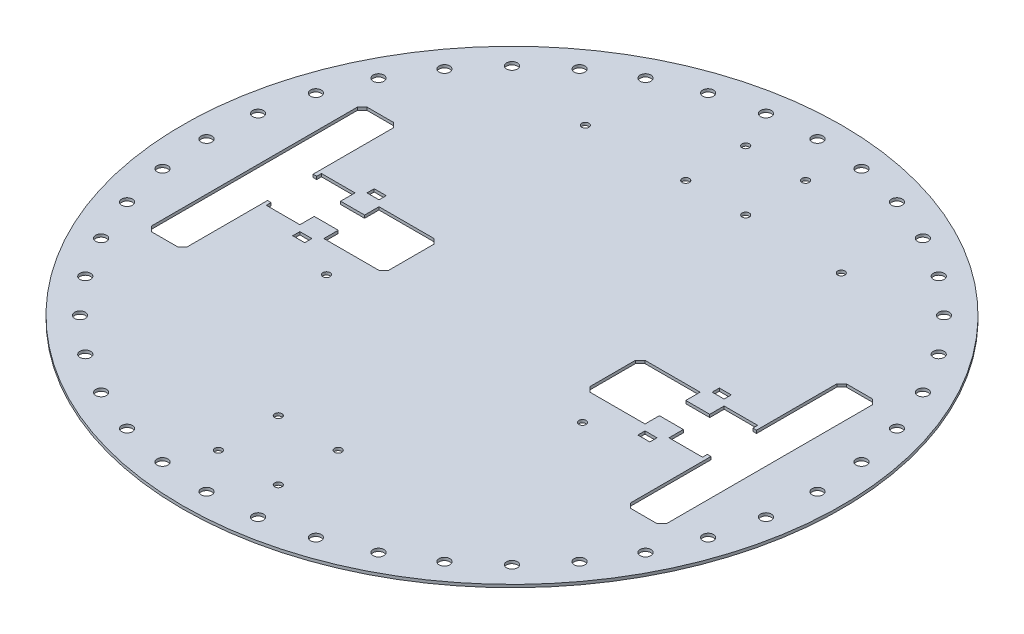
from build123d import *

# Parameters (mm, degrees)
SKETCH1_R           = 137.5
BOSS_EXTRUDE1_DEPTH = 1.2
SKETCH3_R           = 2.25
CUT_EXTRUDE1_DEPTH  = 2.2
CUT_EXTRUDE2_DEPTH  = 1.2
SKETCH5_R           = 1.5
CUT_EXTRUDE3_DEPTH  = 2.2
SKETCH6_R           = 1.5
CUT_EXTRUDE4_DEPTH  = 2.2
SKETCH7_W           = 5
SKETCH7_H           = 3
CUT_EXTRUDE5_DEPTH  = 2.2


with BuildPart() as part:
    # Sketch1 → Boss-Extrude1 (new body)
    with BuildSketch(Plane(origin=(0, 0, 0), x_dir=(1, 0, 0), z_dir=(0, 1, 0))):
        Circle(SKETCH1_R)
    extrude(amount=BOSS_EXTRUDE1_DEPTH)

    # Sketch3 → Cut-Extrude1 (cut, through all)
    with BuildSketch(Plane(origin=(0, 1.2, 0), x_dir=(1, 0, 0), z_dir=(0, 1, 0))):
        with Locations((0, 127.454948432)):
            Circle(SKETCH3_R)
        with Locations((19.938346675, 125.885766517)):
            Circle(SKETCH3_R)
        with Locations((39.385745083, 121.21685924)):
            Circle(SKETCH3_R)
        with Locations((57.863335733, 113.563190593)):
            Circle(SKETCH3_R)
        with Locations((74.91613902, 103.113219299)):
            Circle(SKETCH3_R)
        with Locations((90.124258332, 90.124258332)):
            Circle(SKETCH3_R)
        with Locations((103.113219299, 74.91613902)):
            Circle(SKETCH3_R)
        with Locations((113.563190593, 57.863335733)):
            Circle(SKETCH3_R)
        with Locations((121.21685924, 39.385745083)):
            Circle(SKETCH3_R)
        with Locations((125.885766517, 19.938346675)):
            Circle(SKETCH3_R)
        with Locations((127.454948432, 0)):
            Circle(SKETCH3_R)
        with Locations((125.885766517, -19.938346675)):
            Circle(SKETCH3_R)
        with Locations((121.21685924, -39.385745083)):
            Circle(SKETCH3_R)
        with Locations((113.563190593, -57.863335733)):
            Circle(SKETCH3_R)
        with Locations((103.113219299, -74.91613902)):
            Circle(SKETCH3_R)
        with Locations((90.124258332, -90.124258332)):
            Circle(SKETCH3_R)
        with Locations((74.91613902, -103.113219299)):
            Circle(SKETCH3_R)
        with Locations((57.863335733, -113.563190593)):
            Circle(SKETCH3_R)
        with Locations((39.385745083, -121.21685924)):
            Circle(SKETCH3_R)
        with Locations((19.938346675, -125.885766517)):
            Circle(SKETCH3_R)
        with Locations((0, -127.454948432)):
            Circle(SKETCH3_R)
        with Locations((-19.938346675, -125.885766517)):
            Circle(SKETCH3_R)
        with Locations((-39.385745083, -121.21685924)):
            Circle(SKETCH3_R)
        with Locations((-57.863335733, -113.563190593)):
            Circle(SKETCH3_R)
        with Locations((-74.91613902, -103.113219299)):
            Circle(SKETCH3_R)
        with Locations((-90.124258332, -90.124258332)):
            Circle(SKETCH3_R)
        with Locations((-103.113219299, -74.91613902)):
            Circle(SKETCH3_R)
        with Locations((-113.563190593, -57.863335733)):
            Circle(SKETCH3_R)
        with Locations((-121.21685924, -39.385745083)):
            Circle(SKETCH3_R)
        with Locations((-125.885766517, -19.938346675)):
            Circle(SKETCH3_R)
        with Locations((-127.454948432, 0)):
            Circle(SKETCH3_R)
        with Locations((-125.885766517, 19.938346675)):
            Circle(SKETCH3_R)
        with Locations((-121.21685924, 39.385745083)):
            Circle(SKETCH3_R)
        with Locations((-113.563190593, 57.863335733)):
            Circle(SKETCH3_R)
        with Locations((-103.113219299, 74.91613902)):
            Circle(SKETCH3_R)
        with Locations((-90.124258332, 90.124258332)):
            Circle(SKETCH3_R)
        with Locations((-74.91613902, 103.113219299)):
            Circle(SKETCH3_R)
        with Locations((-57.863335733, 113.563190593)):
            Circle(SKETCH3_R)
        with Locations((-39.385745083, 121.21685924)):
            Circle(SKETCH3_R)
        with Locations((-19.938346675, 125.885766517)):
            Circle(SKETCH3_R)
    extrude(amount=-CUT_EXTRUDE1_DEPTH, mode=Mode.SUBTRACT)

    # Sketch4 → Cut-Extrude2 (cut)
    with BuildSketch(Plane(origin=(0, 1.2, 0), x_dir=(1, 0, 0), z_dir=(0, 1, 0))):
        Polygon((-107.5, -43), (-107.5, 43), (-105.5, 45), (-94.5, 45), (-92.5, 43), (-92.5, 9.5), (-91, 9.5), (-91, 11.5), (-77, 11.5), (-77, 5.5), (-67, 5.5), (-67, 11.5), (-44, 11.5), (-42, 9.5), (-42, -9.5), (-44, -11.5), (-67, -11.5), (-67, -5.5), (-77, -5.5), (-77, -11.5), (-91, -11.5), (-91, -9.5), (-92.5, -9.5), (-92.5, -43), (-94.5, -45), (-105.5, -45), align=None)
        Polygon((94.5, -45), (92.5, -43), (92.5, -9.5), (91, -9.5), (91, -11.5), (77, -11.5), (77, -5.5), (67, -5.5), (67, -11.5), (44, -11.5), (42, -9.5), (42, 9.5), (44, 11.5), (67, 11.5), (67, 5.5), (77, 5.5), (77, 11.5), (91, 11.5), (91, 9.5), (92.5, 9.5), (92.5, 43), (94.5, 45), (105.5, 45), (107.5, 43), (107.5, -43), (105.5, -45), align=None)
    extrude(amount=-CUT_EXTRUDE2_DEPTH, mode=Mode.SUBTRACT)

    # Sketch5 → Cut-Extrude3 (cut, through all)
    with BuildSketch(Plane(origin=(0, 1.2, 0), x_dir=(1, 0, 0), z_dir=(0, 1, 0))):
        with Locations((-53.4, 84)):
            Circle(SKETCH5_R)
        with Locations((53.4, 84)):
            Circle(SKETCH5_R)
        with Locations((53.4, -24)):
            Circle(SKETCH5_R)
        with Locations((-53.4, -24)):
            Circle(SKETCH5_R)
    extrude(amount=-CUT_EXTRUDE3_DEPTH, mode=Mode.SUBTRACT)

    # Sketch6 → Cut-Extrude4 (cut, through all)
    with BuildSketch(Plane(origin=(0, 1.2, 0), x_dir=(1, 0, 0), z_dir=(0, 1, 0))):
        with Locations((-12.5, 110)):
            Circle(SKETCH6_R)
        with Locations((12.5, 110)):
            Circle(SKETCH6_R)
        with Locations((12.5, 85)):
            Circle(SKETCH6_R)
        with Locations((-12.5, 85)):
            Circle(SKETCH6_R)
        with Locations((-12.5, -85)):
            Circle(SKETCH6_R)
        with Locations((12.5, -85)):
            Circle(SKETCH6_R)
        with Locations((12.5, -110)):
            Circle(SKETCH6_R)
        with Locations((-12.5, -110)):
            Circle(SKETCH6_R)
    extrude(amount=-CUT_EXTRUDE4_DEPTH, mode=Mode.SUBTRACT)

    # Sketch7 → Cut-Extrude5 (cut, through all)
    with BuildSketch(Plane(origin=(0, 1.2, 0), x_dir=(1, 0, 0), z_dir=(0, 1, 0))):
        with Locations((-72, 15.5)):
            Rectangle(SKETCH7_W, SKETCH7_H)
        with Locations((-72, -15.5)):
            Rectangle(SKETCH7_W, SKETCH7_H)
        with Locations((72, -15.5)):
            Rectangle(SKETCH7_W, SKETCH7_H)
        with Locations((72, 15.5)):
            Rectangle(SKETCH7_W, SKETCH7_H)
    extrude(amount=-CUT_EXTRUDE5_DEPTH, mode=Mode.SUBTRACT)


solid = part.part
